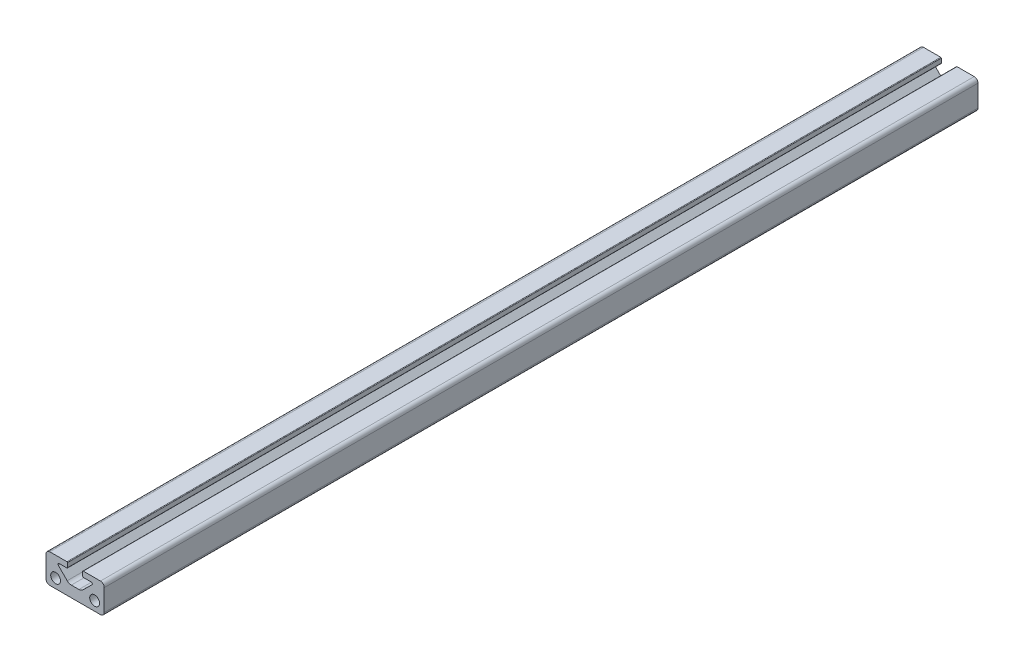
from build123d import *

# Parameters (mm, degrees)
SKETCH3_R           = 2.1463
BOSS_EXTRUDE1_DEPTH = 190.5
FILLET1_R           = 0.254


with BuildPart() as part:
    # Sketch3 → Boss-Extrude1 (new body, symmetric)
    with BuildSketch(Plane.XY):
        with BuildLine():
            Line((-11.049, 12.7), (-3.302, 12.7))
            Line((-3.302, 12.7), (-3.302, 10.328863887))
            Line((-3.302, 10.328863887), (-6.985, 10.328863887))
            ThreePointArc((-6.985, 10.328863887), (-7.454330803, 10.01526707), (-7.344210245, 9.461653642))
            Line((-7.344210245, 9.461653642), (-3.452505379, 5.569948776))
            ThreePointArc((-3.452505379, 5.569948776), (-2.628470073, 5.019345987), (-1.656454155, 4.826))
            Line((-1.656454155, 4.826), (1.656454155, 4.826))
            ThreePointArc((1.656454155, 4.826), (2.628470073, 5.019345987), (3.452505379, 5.569948776))
            Line((3.452505379, 5.569948776), (7.344210245, 9.461653642))
            ThreePointArc((7.344210245, 9.461653642), (7.454330803, 10.01526707), (6.985, 10.328863887))
            Line((6.985, 10.328863887), (3.302, 10.328863887))
            Line((3.302, 10.328863887), (3.302, 12.7))
            Line((3.302, 12.7), (11.049, 12.7))
            ThreePointArc((11.049, 12.7), (12.216433296, 12.216433296), (12.7, 11.049))
            Line((12.7, 11.049), (12.7, 1.651))
            ThreePointArc((12.7, 1.651), (12.216433296, 0.483566704), (11.049, 0))
            Line((11.049, 0), (-11.049, 0))
            ThreePointArc((-11.049, 0), (-12.216433296, 0.483566704), (-12.7, 1.651))
            Line((-12.7, 1.651), (-12.7, 11.049))
            ThreePointArc((-12.7, 11.049), (-12.216433296, 12.216433296), (-11.049, 12.7))
        make_face()
        with Locations((8.509, 4.064)):
            Circle(SKETCH3_R, mode=Mode.SUBTRACT)
        with Locations((-8.509, 4.064)):
            Circle(SKETCH3_R, mode=Mode.SUBTRACT)
    extrude(amount=BOSS_EXTRUDE1_DEPTH, both=True)

    # Fillet1
    fillet1_edges = [part.edges().sort_by_distance(p)[0] for p in [
        (-3.302, 12.7, 0),
        (-3.302, 10.328863887, 0),
        (3.302, 10.328863887, 0),
        (3.302, 12.7, 0),
    ]]
    fillet(fillet1_edges, radius=FILLET1_R)


solid = part.part
